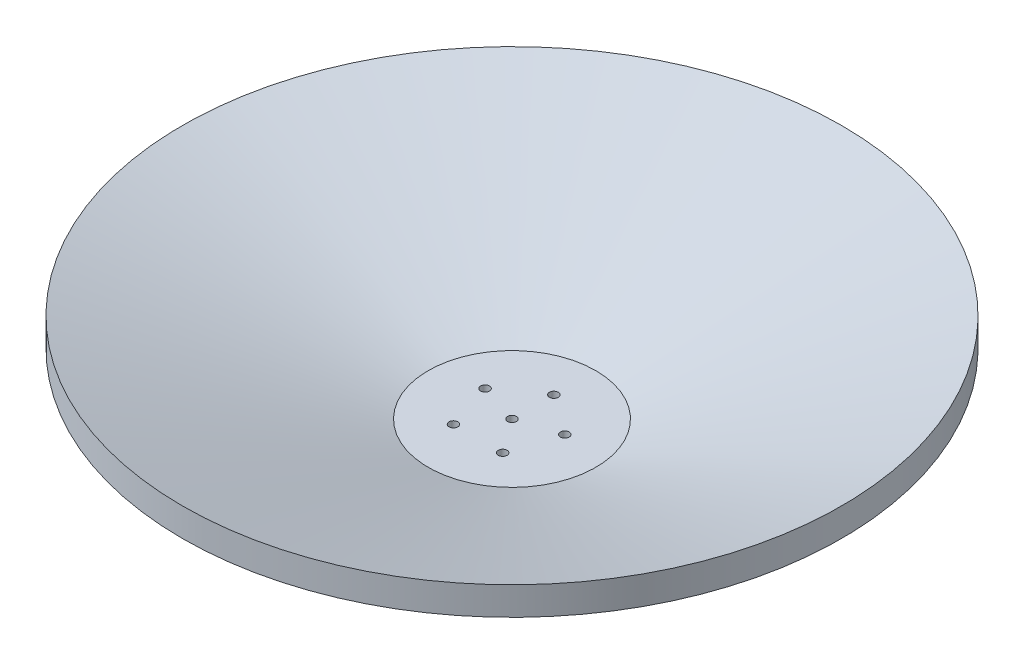
from build123d import *

# Parameters (mm, degrees)
SKETCH2_R          = 0.5
CUT_EXTRUDE1_DEPTH = 18


with BuildPart() as part:
    # Sketch1 → Revolve1 (revolve)
    with BuildSketch(Plane.XY):
        Polygon((0, 0), (10, 0), (37.25, 9.918188884), (37.25, 13.110722201), (36.22393957, 12.737266746), (9.471019058, 3), (0, 3), align=None)
    revolve(axis=Axis((0, 0, 0), (0, 1, 0)))

    # Sketch2 → Cut-Extrude1 (cut)
    with BuildSketch(Plane(origin=(0, 3, 0), x_dir=(1, 0, 0), z_dir=(0, 1, 0))):
        with Locations((0, 4.735509529)):
            Circle(SKETCH2_R)
        Circle(SKETCH2_R)
        with Locations((4.503737195, 1.463352921)):
            Circle(SKETCH2_R)
        with Locations((2.783462663, -3.831107686)):
            Circle(SKETCH2_R)
        with Locations((-2.783462663, -3.831107686)):
            Circle(SKETCH2_R)
        with Locations((-4.503737195, 1.463352921)):
            Circle(SKETCH2_R)
    extrude(amount=-CUT_EXTRUDE1_DEPTH, mode=Mode.SUBTRACT)


solid = part.part
